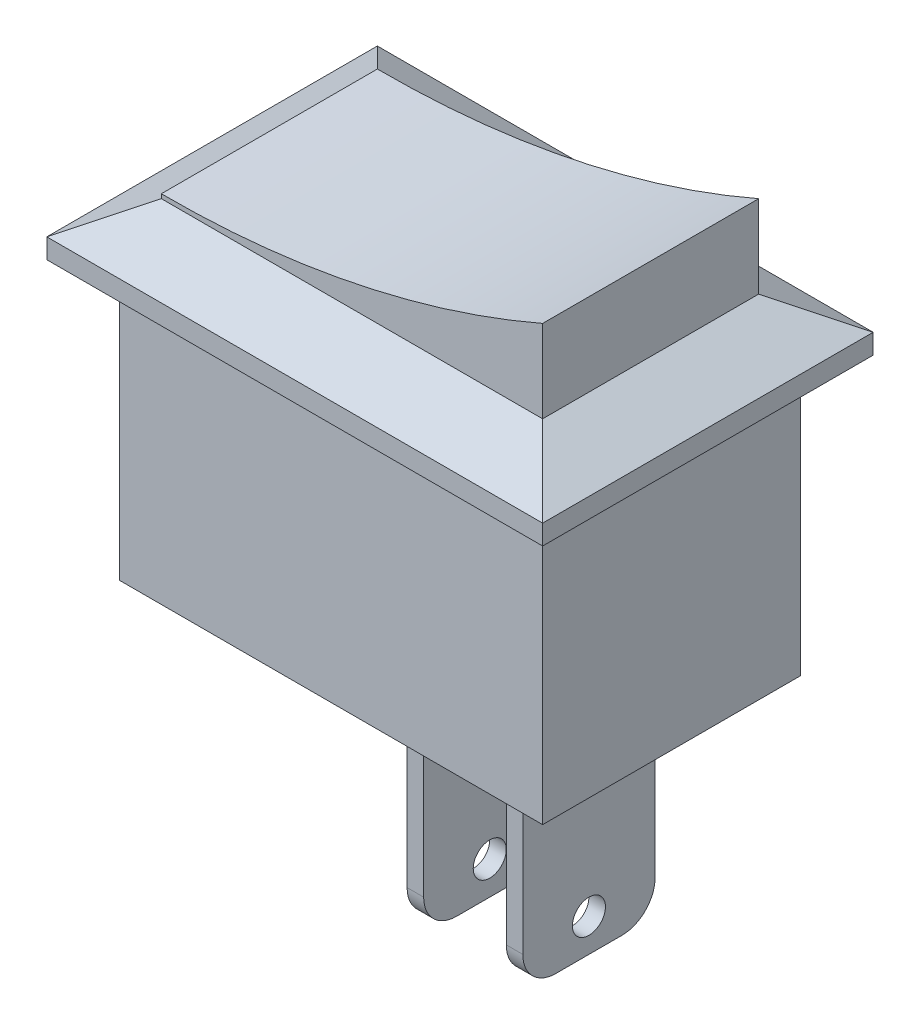
from build123d import *

# Parameters (mm, degrees)
SKETCH1_W               = 15
SKETCH1_H               = 10
BOSS_EXTRUDE1_DEPTH     = 10
SKETCH2_W               = 15
SKETCH2_H               = 10
SKETCH2_W_2             = 12.8
SKETCH2_H_2             = 7.8
CUT_EXTRUDE1_DEPTH      = 8.4
CHAMFER1_SIZE           = 1
CHAMFER1_SIZE2          = 1.732050808
CHAMFER1_PART_2_SIZE    = 1
CHAMFER1_PART_2_SIZE2   = 1.732050808
CHAMFER1_PART_3_SIZE    = 1
CHAMFER1_PART_3_SIZE2   = 1.732050808
CHAMFER1_PART_4_SIZE    = 1
CHAMFER1_PART_4_SIZE2   = 1.732050808
SKETCH3_W               = 0.5
SKETCH3_H               = 4
EXTRUDE_THIN1_DEPTH     = 6.6
FILLET1_R               = 1
SKETCH4_R               = 0.5
CUT_EXTRUDE2_DEPTH      = 6.6
SKETCH5_W               = 11.535898384
SKETCH5_H               = 6.535898384
BOSS_EXTRUDE2_DEPTH     = 2.5
CUT_EXTRUDE5_DEPTH      = 2.732050808
CUT_EXTRUDE5_DEPTH_BACK = 7.5


with BuildPart() as part:
    # Sketch1 → Boss-Extrude1 (new body)
    with BuildSketch(Plane(origin=(0, 0, 0), x_dir=(1, 0, 0), z_dir=(0, 1, 0))):
        Rectangle(SKETCH1_W, SKETCH1_H)
    extrude(amount=BOSS_EXTRUDE1_DEPTH)

    # Sketch2 → Cut-Extrude1 (cut)
    with BuildSketch(Plane.XZ):
        Rectangle(SKETCH2_W, SKETCH2_H)
        Rectangle(SKETCH2_W_2, SKETCH2_H_2, mode=Mode.SUBTRACT)
    extrude(amount=-CUT_EXTRUDE1_DEPTH, mode=Mode.SUBTRACT)

    # Chamfer1
    chamfer1_edges = [part.edges().sort_by_distance(p)[0] for p in [
        (-7.5, 10, 0),
    ]]
    chamfer1_side = [part.faces().sort_by_distance(p)[0] for p in [
        (-7.5, 9.2, 0),
    ]]
    chamfer(chamfer1_edges, length=CHAMFER1_SIZE, length2=CHAMFER1_SIZE2, reference=chamfer1_side[0])

    # Chamfer1 part 2
    chamfer1_part_2_edges = [part.edges().sort_by_distance(p)[0] for p in [
        (0, 10, 5),
    ]]
    chamfer1_part_2_side = [part.faces().sort_by_distance(p)[0] for p in [
        (0, 9.2, 5),
    ]]
    chamfer(chamfer1_part_2_edges, length=CHAMFER1_PART_2_SIZE, length2=CHAMFER1_PART_2_SIZE2, reference=chamfer1_part_2_side[0])

    # Chamfer1 part 3
    chamfer1_part_3_edges = [part.edges().sort_by_distance(p)[0] for p in [
        (7.5, 10, 0),
    ]]
    chamfer1_part_3_side = [part.faces().sort_by_distance(p)[0] for p in [
        (7.5, 9.2, 0),
    ]]
    chamfer(chamfer1_part_3_edges, length=CHAMFER1_PART_3_SIZE, length2=CHAMFER1_PART_3_SIZE2, reference=chamfer1_part_3_side[0])

    # Chamfer1 part 4
    chamfer1_part_4_edges = [part.edges().sort_by_distance(p)[0] for p in [
        (0, 10, -5),
    ]]
    chamfer1_part_4_side = [part.faces().sort_by_distance(p)[0] for p in [
        (0, 9.2, -5),
    ]]
    chamfer(chamfer1_part_4_edges, length=CHAMFER1_PART_4_SIZE, length2=CHAMFER1_PART_4_SIZE2, reference=chamfer1_part_4_side[0])

    # Sketch3 → Extrude-Thin1 (add)
    with BuildSketch(Plane.XZ):
        with Locations((3.65, 0)):
            Rectangle(SKETCH3_W, SKETCH3_H)
        with Locations((0.65, 0)):
            Rectangle(SKETCH3_W, SKETCH3_H)
    extrude(amount=EXTRUDE_THIN1_DEPTH)

    # Fillet1
    fillet1_edges = [part.edges().sort_by_distance(p)[0] for p in [
        (3.65, -6.6, 2),
        (3.65, -6.6, -2),
        (0.65, -6.6, 2),
        (0.65, -6.6, -2),
    ]]
    fillet(fillet1_edges, radius=FILLET1_R)

    # Sketch4 → Cut-Extrude2 (cut)
    with BuildSketch(Plane.ZY.offset(-0.4)):
        with Locations((0, -5.6)):
            Circle(SKETCH4_R)
    extrude(amount=-CUT_EXTRUDE2_DEPTH, mode=Mode.SUBTRACT)

    # Sketch5 → Boss-Extrude2 (add)
    with BuildSketch(Plane(origin=(0, 10, 0), x_dir=(1, 0, 0), z_dir=(0, 1, 0))):
        Rectangle(SKETCH5_W, SKETCH5_H)
    extrude(amount=BOSS_EXTRUDE2_DEPTH)

    # Sketch6 → Cut-Extrude5 (cut, two sides)
    with BuildSketch(Plane.XY.offset(3.267949192)) as cut_extrude5_sk:
        with BuildLine():
            Line((57.587759611, 35.04655449), (5.767949192, 12.5))
            ThreePointArc((5.767949192, 12.5), (0.123547764, 10.713329317), (-5.767949192, 10.128758351))
            Line((-5.767949192, 10.128758351), (-62.279560483, 10.40743474))
            Line((-62.279560483, 10.40743474), (-85.036348275, 121.117362453))
            Line((-85.036348275, 121.117362453), (34.83097182, 145.756482204))
            Line((34.83097182, 145.756482204), (57.587759611, 35.04655449))
        make_face()
    extrude(amount=CUT_EXTRUDE5_DEPTH, mode=Mode.SUBTRACT)
    extrude(cut_extrude5_sk.sketch, amount=-CUT_EXTRUDE5_DEPTH_BACK, mode=Mode.SUBTRACT)


solid = part.part
